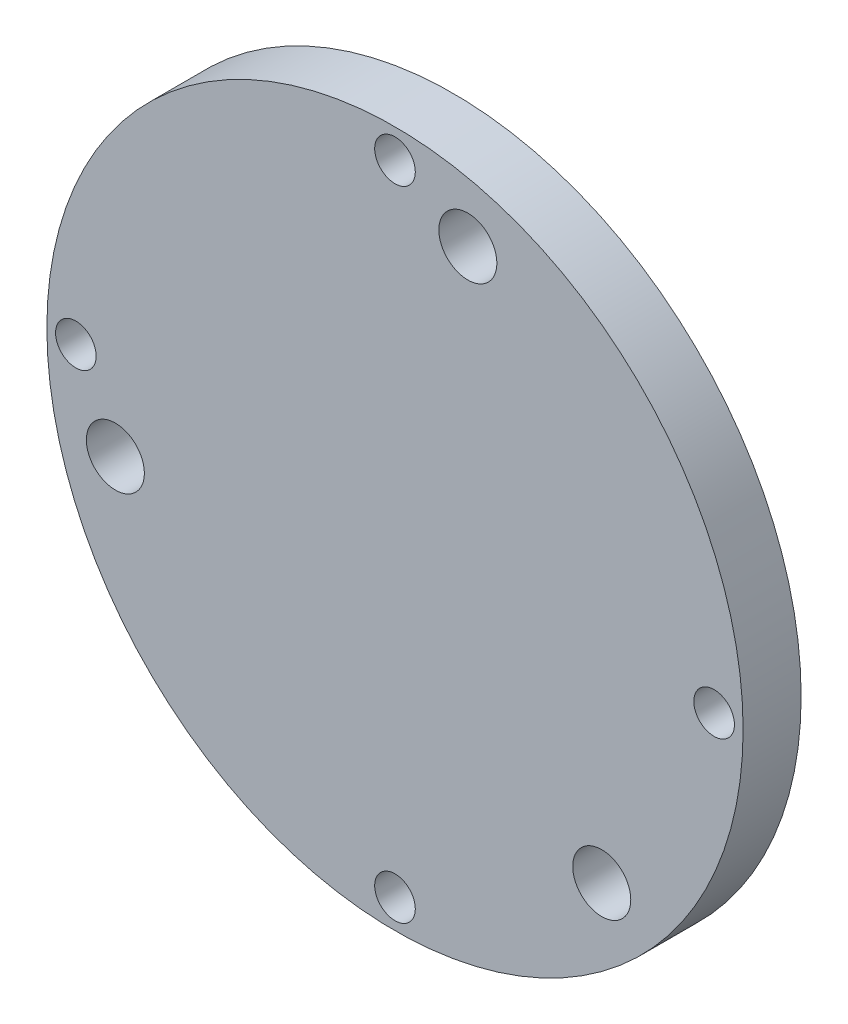
from build123d import *

# Parameters (mm, degrees)
SKETCH1_R           = 30
SKETCH1_R_2         = 1.75
SKETCH1_R_3         = 2.5
BOSS_EXTRUDE1_DEPTH = 5


with BuildPart() as part:
    # Sketch1 → Boss-Extrude1 (new body)
    with BuildSketch(Plane.XY):
        Circle(SKETCH1_R)
        with Locations((0, 27.5)):
            Circle(SKETCH1_R_2, mode=Mode.SUBTRACT)
        with Locations((27.5, 0)):
            Circle(SKETCH1_R_2, mode=Mode.SUBTRACT)
        with Locations((0, -27.5)):
            Circle(SKETCH1_R_2, mode=Mode.SUBTRACT)
        with Locations((-27.5, 0)):
            Circle(SKETCH1_R_2, mode=Mode.SUBTRACT)
        with Locations((6.278593331, 24.198745128)):
            Circle(SKETCH1_R_3, mode=Mode.SUBTRACT)
        with Locations((17.817431356, -17.536793889)):
            Circle(SKETCH1_R_3, mode=Mode.SUBTRACT)
        with Locations((-24.096024686, -6.66195124)):
            Circle(SKETCH1_R_3, mode=Mode.SUBTRACT)
    extrude(amount=BOSS_EXTRUDE1_DEPTH)


solid = part.part
